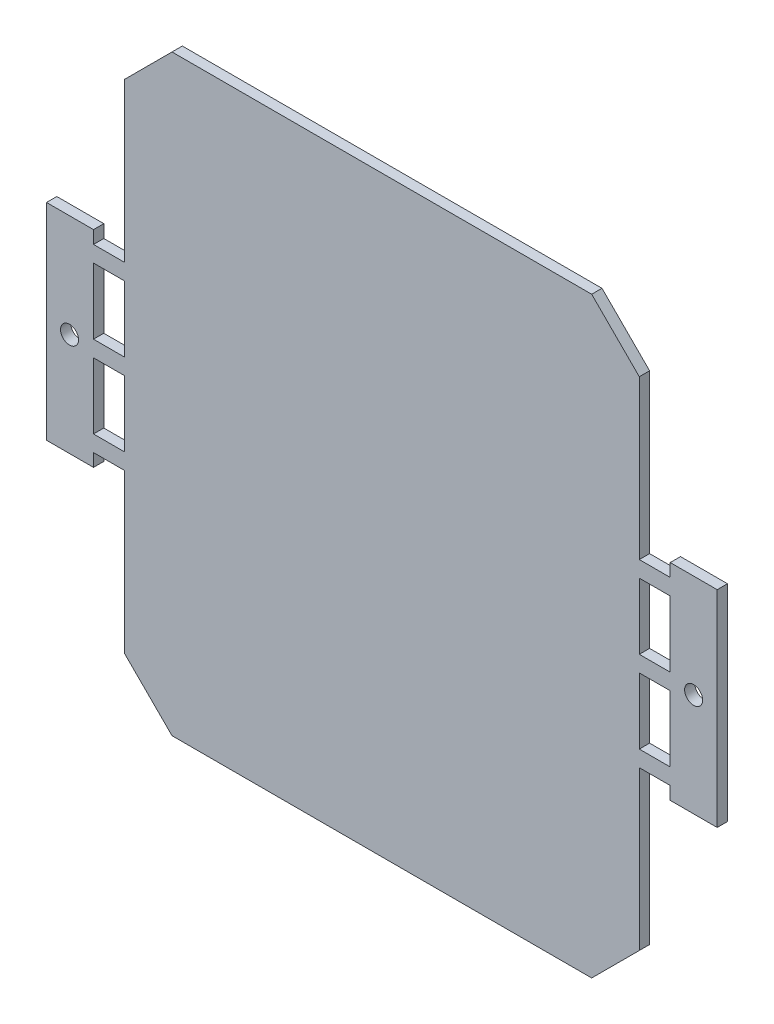
from build123d import *

# Parameters (mm, degrees)
SKETCH1_R           = 0.7
SKETCH1_W           = 2.4
SKETCH1_H           = 5.125
BOSS_EXTRUDE1_DEPTH = 0.8


with BuildPart() as part:
    # Sketch1 → Boss-Extrude1 (new body)
    with BuildSketch(Plane.XY):
        Polygon((0, 30), (2.4, 30), (2.4, 31), (6.05, 31), (6.05, 15), (2.4, 15), (2.4, 16), (0, 16), (0, 3.7), (-3.7, 0), (-36.3, 0), (-40, 3.7), (-40, 16), (-42.4, 16), (-42.4, 15), (-46.05, 15), (-46.05, 31), (-42.4, 31), (-42.4, 30), (-40, 30), (-40, 42.3), (-36.3, 46), (-3.7, 46), (0, 42.3), align=None)
        with Locations((4.21811613, 23)):
            Circle(SKETCH1_R, mode=Mode.SUBTRACT)
        with Locations((-44.262582218, 23)):
            Circle(SKETCH1_R, mode=Mode.SUBTRACT)
        with Locations((1.2, 19.8125)):
            Rectangle(SKETCH1_W, SKETCH1_H, mode=Mode.SUBTRACT)
        with Locations((1.2, 26.1875)):
            Rectangle(SKETCH1_W, SKETCH1_H, mode=Mode.SUBTRACT)
        with Locations((-41.2, 26.1875)):
            Rectangle(SKETCH1_W, SKETCH1_H, mode=Mode.SUBTRACT)
        with Locations((-41.2, 19.8125)):
            Rectangle(SKETCH1_W, SKETCH1_H, mode=Mode.SUBTRACT)
    extrude(amount=BOSS_EXTRUDE1_DEPTH)


solid = part.part
